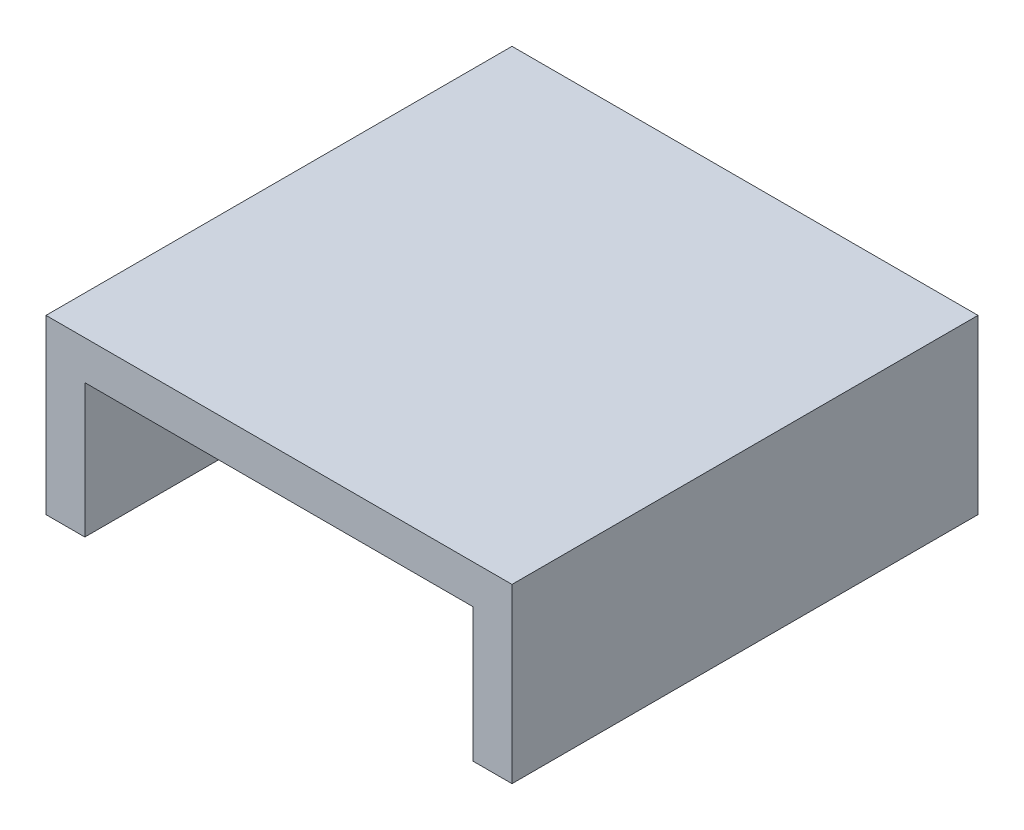
from build123d import *

# Parameters (mm, degrees)
BOSS_EXTRUDE1_DEPTH = 54


with BuildPart() as part:
    # Sketch2 → Boss-Extrude1 (new body)
    with BuildSketch(Plane.XY):
        Polygon((27, 0), (-27, 0), (-27, -20), (-22.5, -20), (-22.5, -4.5), (22.5, -4.5), (22.5, -20), (27, -20), align=None)
    extrude(amount=BOSS_EXTRUDE1_DEPTH)


solid = part.part
